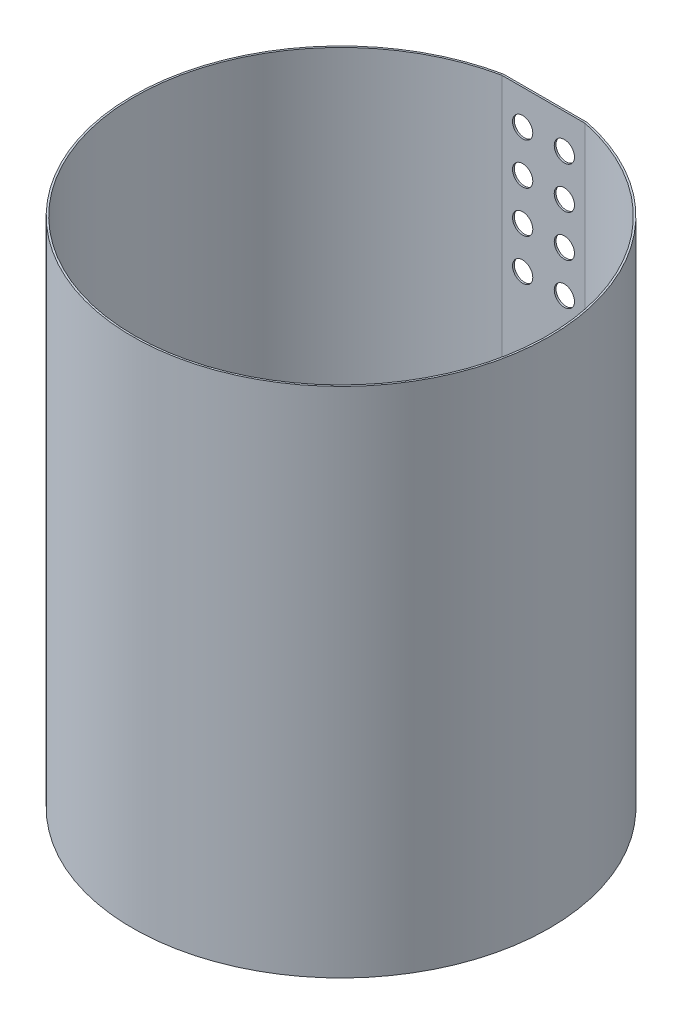
from build123d import *

# Parameters (mm, degrees)
BOSS_EXTRUDE1_DEPTH = 430
SKETCH4_R           = 8.5
CUT_EXTRUDE2_DEPTH  = 1.5
LPATTERN1_COUNT     = 4
LPATTERN1_PITCH     = 35


with BuildPart() as part:
    # Sketch1 → Boss-Extrude1 (new body)
    with BuildSketch(Plane(origin=(0, 0, 0), x_dir=(1, 0, 0), z_dir=(0, 1, 0))):
        with BuildLine():
            Line((-35.152535823, 171.433075062), (35.152535823, 171.433075062))
            ThreePointArc((35.152535823, 171.433075062), (0, -175), (-35.152535823, 171.433075062))
        make_face()
        with BuildLine():
            ThreePointArc((-35, 169.933075062), (0, -173.5), (35, 169.933075062))
            Line((35, 169.933075062), (-35, 169.933075062))
        make_face(mode=Mode.SUBTRACT)
    extrude(amount=BOSS_EXTRUDE1_DEPTH)

    # Sketch4 → Cut-Extrude2 (cut)
    with BuildSketch(Plane(origin=(0, 0, -171.433075062), x_dir=(-1, 0, 0), z_dir=(0, 0, -1))):
        with Locations((-17.5, 401)):
            Circle(SKETCH4_R)
        with Locations((17.5, 401)):
            Circle(SKETCH4_R)
    cut_extrude2 = extrude(amount=-CUT_EXTRUDE2_DEPTH, mode=Mode.SUBTRACT)

    # LPattern1: Cut-Extrude2 ×4
    with Locations(*[(0, -i * LPATTERN1_PITCH, 0) for i in range(1, LPATTERN1_COUNT)]):
        add(cut_extrude2, mode=Mode.SUBTRACT)


solid = part.part
